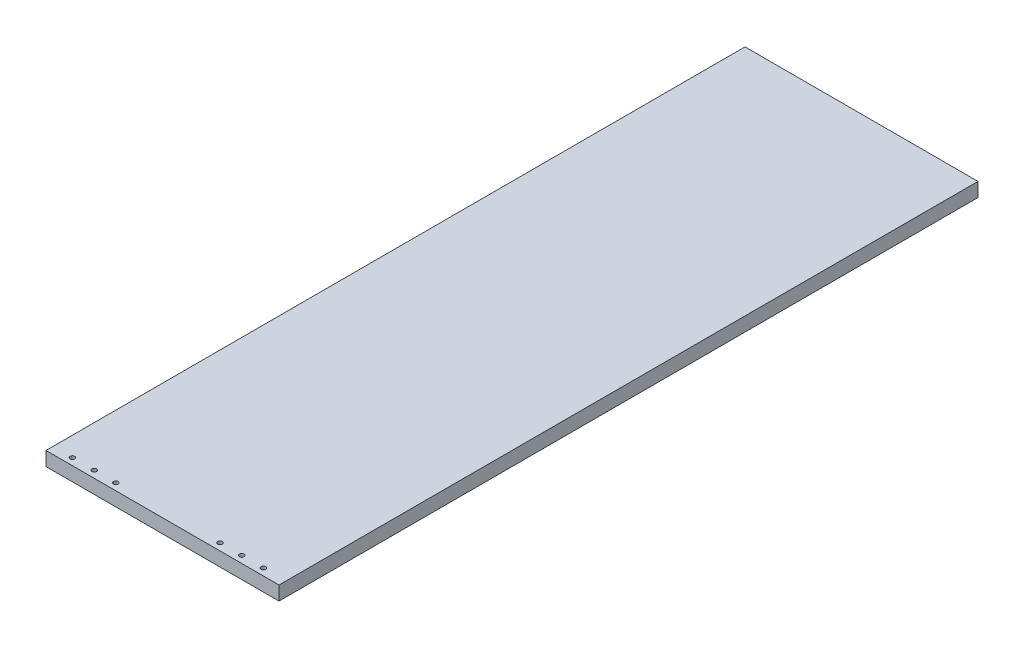
from build123d import *

# Parameters (mm, degrees)
SKETCH_2_W          = 300
SKETCH_2_H          = 900
EXTRUDE_1_DEPTH     = 18
SKETCH_3_R          = 3
CUT_EXTRUDE_1_DEPTH = 9


with BuildPart() as part:
    # Эскиз2 → Бобышка-Вытянуть1 (new body)
    with BuildSketch(Plane(origin=(0, 0, 0), x_dir=(1, 0, 0), z_dir=(0, 1, 0))):
        with Locations((150, 450)):
            Rectangle(SKETCH_2_W, SKETCH_2_H)
    extrude(amount=EXTRUDE_1_DEPTH)

    # Эскиз3 → Вырез-Вытянуть1 (cut)
    with BuildSketch(Plane(origin=(0, 18, 0), x_dir=(1, 0, 0), z_dir=(0, 1, 0))):
        with Locations((25, 9)):
            Circle(SKETCH_3_R)
        with Locations((53, 9)):
            Circle(SKETCH_3_R)
        with Locations((81, 9)):
            Circle(SKETCH_3_R)
        with Locations((215, 9)):
            Circle(SKETCH_3_R)
        with Locations((243, 9)):
            Circle(SKETCH_3_R)
        with Locations((271, 9)):
            Circle(SKETCH_3_R)
    extrude(amount=-CUT_EXTRUDE_1_DEPTH, mode=Mode.SUBTRACT)


solid = part.part
